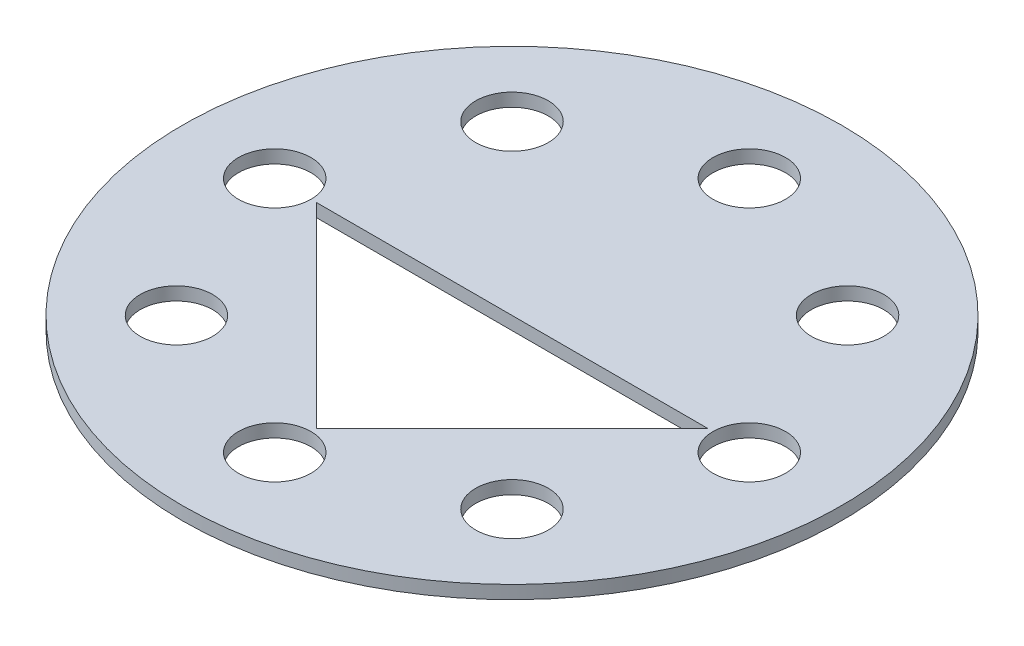
from build123d import *

# Parameters (mm, degrees)
SKETCH_1_R               = 25
EXTRUDE_2_DEPTH          = 1
SKETCH_2_R               = 1.5
CUT_EXTRUDE_1_DEPTH      = 1
PATTERN_CIRCULAR_1_COUNT = 8
CUT_EXTRUDE_2_DEPTH      = 1
EXTRUDE_3_DEPTH          = 1
SKETCH_5_R               = 25
EXTRUDE_5_DEPTH          = 2
SKETCH_6_R               = 1.5
CUT_EXTRUDE_3_DEPTH      = 2
PATTERN_CIRCULAR_2_COUNT = 8
SKETCH_7_R               = 25
EXTRUDE_6_DEPTH          = 2
SKETCH_8_R               = 2.75
CUT_EXTRUDE_4_DEPTH      = 2
PATTERN_CIRCULAR_3_COUNT = 8
EXTRUDE_8_DEPTH          = 2
SKETCH_11_R              = 25
CUT_EXTRUDE_6_DEPTH      = 4


with BuildPart() as part:
    # 草图1 → 凸台-拉伸2 (new body)
    with BuildSketch(Plane(origin=(0, 0, 0), x_dir=(1, 0, 0), z_dir=(0, 1, 0))):
        Circle(SKETCH_1_R)
    extrude(amount=EXTRUDE_2_DEPTH)

    # 草图2 → 切除-拉伸1 (cut)
    with BuildSketch(Plane(origin=(0, 1, 0), x_dir=(1, 0, 0), z_dir=(0, 1, 0))):
        with Locations((18, 0)):
            Circle(SKETCH_2_R)
    cut_extrude_1 = extrude(amount=-CUT_EXTRUDE_1_DEPTH, mode=Mode.SUBTRACT)

    # 阵列(圆周)1: 切除-拉伸1 ×8 about axis
    pattern_circular_1_axis = Axis((0, 0, 0), (0, 1, 0))
    for i in range(1, PATTERN_CIRCULAR_1_COUNT):
        add(cut_extrude_1.rotate(pattern_circular_1_axis, i * 360 / PATTERN_CIRCULAR_1_COUNT), mode=Mode.SUBTRACT)

    # 草图3 → 切除-拉伸2 (cut)
    with BuildSketch(Plane(origin=(0, 1, 0), x_dir=(1, 0, 0), z_dir=(0, 1, 0))):
        Polygon((-15.202795796, 0), (15.202795796, 0), (0, -15.202795796), align=None)
    extrude(amount=-CUT_EXTRUDE_2_DEPTH, mode=Mode.SUBTRACT)

    # 草图4 → 凸台-拉伸3 (add)
    with BuildSketch(Plane(origin=(0, 1, 0), x_dir=(1, 0, 0), z_dir=(0, 1, 0))):
        Polygon((0, -14.849242405), (14.849242405, 0), (15.202795796, 0), (0, -15.202795796), (-15.202795796, 0), (-14.849242405, 0), align=None)
    extrude(amount=-EXTRUDE_3_DEPTH)

    # 草图5 → 凸台-拉伸5 (add)
    with BuildSketch(Plane.XZ):
        Circle(SKETCH_5_R)
    extrude(amount=EXTRUDE_5_DEPTH)

    # 草图6 → 切除-拉伸3 (cut)
    with BuildSketch(Plane(origin=(0, 0, 0), x_dir=(1, 0, 0), z_dir=(0, 1, 0))):
        with Locations((18, 0)):
            Circle(SKETCH_6_R)
    cut_extrude_3 = extrude(amount=-CUT_EXTRUDE_3_DEPTH, mode=Mode.SUBTRACT)

    # 阵列(圆周)2: 切除-拉伸3 ×8 about axis
    pattern_circular_2_axis = Axis((0, 0, 0), (0, 1, 0))
    for i in range(1, PATTERN_CIRCULAR_2_COUNT):
        add(cut_extrude_3.rotate(pattern_circular_2_axis, i * 360 / PATTERN_CIRCULAR_2_COUNT), mode=Mode.SUBTRACT)

    # 草图7 → 凸台-拉伸6 (add)
    with BuildSketch(Plane(origin=(0, 1, 0), x_dir=(1, 0, 0), z_dir=(0, 1, 0))):
        Circle(SKETCH_7_R)
        Polygon((-14.849242405, 0), (14.849242405, 0), (0, -14.849242405), align=None, mode=Mode.SUBTRACT)
    extrude(amount=EXTRUDE_6_DEPTH)

    # 草图8 → 切除-拉伸4 (cut)
    with BuildSketch(Plane(origin=(0, 1, 0), x_dir=(1, 0, 0), z_dir=(0, 1, 0))):
        with Locations((18, 0)):
            Circle(SKETCH_8_R)
    cut_extrude_4 = extrude(amount=CUT_EXTRUDE_4_DEPTH, mode=Mode.SUBTRACT)

    # 阵列(圆周)3: 切除-拉伸4 ×8 about axis
    pattern_circular_3_axis = Axis((0, 0, 0), (0, 1, 0))
    for i in range(1, PATTERN_CIRCULAR_3_COUNT):
        add(cut_extrude_4.rotate(pattern_circular_3_axis, i * 360 / PATTERN_CIRCULAR_3_COUNT), mode=Mode.SUBTRACT)

    # 草图9 → 凸台-拉伸8 (add)
    with BuildSketch(Plane(origin=(0, 0, 0), x_dir=(1, 0, 0), z_dir=(0, 1, 0))):
        Polygon((-14.849242405, 0), (14.849242405, 0), (0, -14.849242405), align=None)
    extrude(amount=EXTRUDE_8_DEPTH)

    # 草图11 → 切除-拉伸6 (cut)
    with BuildSketch(Plane.XZ.offset(2)):
        Circle(SKETCH_11_R)
    extrude(amount=-CUT_EXTRUDE_6_DEPTH, mode=Mode.SUBTRACT)


solid = part.part
